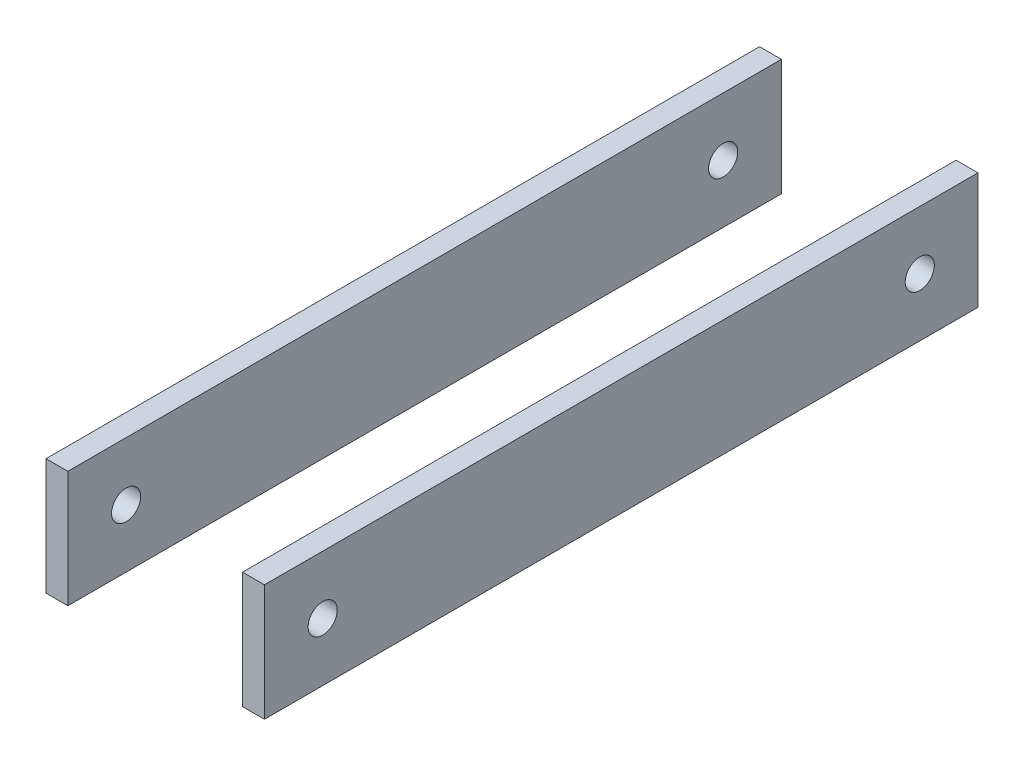
from build123d import *

# Parameters (mm, degrees)
SKETCH1_W           = 311.15
SKETCH1_H           = 50.8
SKETCH1_R           = 6.35
BOSS_EXTRUDE1_DEPTH = 47.625
SKETCH2_W           = 76.2
SKETCH2_H           = 50.8
CUT_EXTRUDE1_DEPTH  = 311.15


with BuildPart() as part:
    # Sketch1 → Boss-Extrude1 (new body, symmetric)
    with BuildSketch(Plane(origin=(0, 0, 0), x_dir=(0, 0, -1), z_dir=(1, 0, 0))):
        with Locations((3.175, 0)):
            Rectangle(SKETCH1_W, SKETCH1_H)
        with Locations((-127, 0)):
            Circle(SKETCH1_R, mode=Mode.SUBTRACT)
        with Locations((133.35, 0)):
            Circle(SKETCH1_R, mode=Mode.SUBTRACT)
    extrude(amount=BOSS_EXTRUDE1_DEPTH, both=True)

    # Sketch2 → Cut-Extrude1 (cut)
    with BuildSketch(Plane.XY.offset(152.4)):
        Rectangle(SKETCH2_W, SKETCH2_H)
    extrude(amount=-CUT_EXTRUDE1_DEPTH, mode=Mode.SUBTRACT)


solid = part.part
